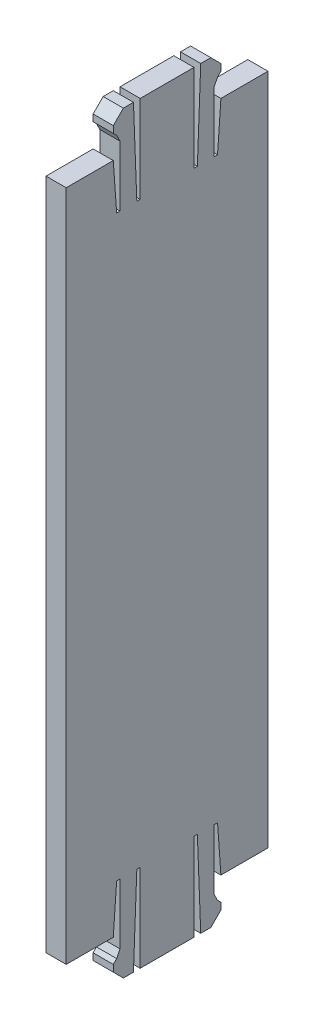
from build123d import *

# Parameters (mm, degrees)
BOSS_EXTRUDE1_DEPTH = 3


with BuildPart() as part:
    # Sketch1 → Boss-Extrude1 (new body)
    with BuildSketch(Plane(origin=(0, 0, 0), x_dir=(0, 0, -1), z_dir=(1, 0, 0))):
        Polygon((-15, -50), (-8, -50), (-7.5, -42.997828908), (-7, -42.997828908), (-7, -51.997828908), (-7.5, -52.997828908), (-8, -53.497828908), (-8, -54.497828908), (-6.5, -55.997828908), (-5, -55.997828908), (-4.5, -42.997828908), (-4, -42.997828908), (-4, -55.997828908), (4, -55.997828908), (4, -42.997828908), (4.5, -42.997828908), (5, -55.997828908), (6.5, -55.997828908), (8, -54.497828908), (8, -53.497828908), (7.5, -52.997828908), (7, -51.997828908), (7, -42.997828908), (7.5, -42.997828908), (8, -50), (15, -50), (15, 50), (8, 50), (7.5, 42.997828908), (7, 42.997828908), (7, 51.997828908), (7.5, 52.997828908), (8, 53.497828908), (8, 54.497828908), (6.5, 55.997828908), (5, 55.997828908), (4.5, 42.997828908), (4, 42.997828908), (4, 55.997828908), (-4, 55.997828908), (-4, 42.997828908), (-4.5, 42.997828908), (-5, 55.997828908), (-6.5, 55.997828908), (-8, 54.497828908), (-8, 53.497828908), (-7.5, 52.997828908), (-7, 51.997828908), (-7, 42.997828908), (-7.5, 42.997828908), (-8, 50), (-15, 50), align=None)
    extrude(amount=BOSS_EXTRUDE1_DEPTH)


solid = part.part
